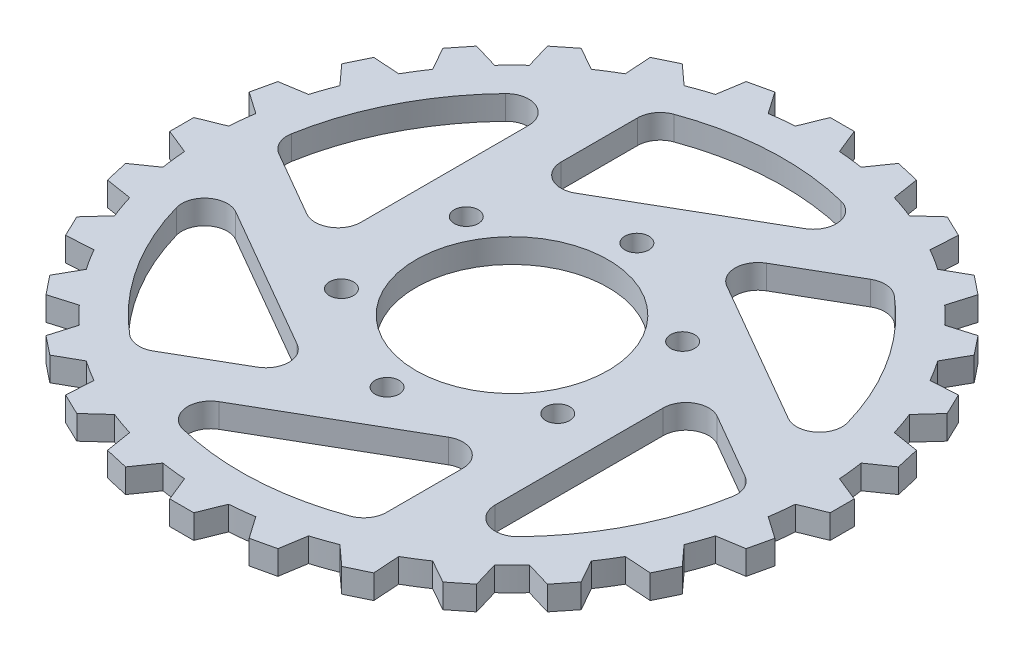
from build123d import *

# Parameters (mm, degrees)
SKETCH1_R           = 40
SKETCH1_R_2         = 5
BOSS_EXTRUDE1_DEPTH = 10


with BuildPart() as part:
    # Sketch1 → Boss-Extrude1 (new body)
    with BuildSketch(Plane(origin=(0, 0, 0), x_dir=(1, 0, 0), z_dir=(0, 1, 0))):
        with BuildLine():
            Line((-5, -137.5), (5, -137.5))
            Line((5, -137.5), (9.173776902, -127.16953966))
            ThreePointArc((9.173776902, -127.16953966), (14.275470703, -126.698306761), (19.354113574, -126.022491198))
            Line((19.354113574, -126.022491198), (25.721988858, -135.165192595))
            Line((25.721988858, -135.165192595), (35.47126798, -132.939983255))
            Line((35.47126798, -132.939983255), (37.241655898, -121.93977639))
            ThreePointArc((37.241655898, -121.93977639), (42.110580399, -120.345124614), (46.91150798, -118.556148803))
            Line((46.91150798, -118.556148803), (55.154169789, -126.052638032))
            Line((55.154169789, -126.052638032), (64.163858468, -121.713800641))
            Line((64.163858468, -121.713800641), (63.44208276, -110.595443555))
            ThreePointArc((63.44208276, -110.595443555), (67.834089756, -107.957335402), (72.11656349, -105.14490606))
            Line((72.11656349, -105.14490606), (81.820690343, -110.619277849))
            Line((81.820690343, -110.619277849), (89.639005168, -104.38437983))
            Line((89.639005168, -104.38437983), (86.46125868, -93.705393374))
            ThreePointArc((86.46125868, -93.705393374), (90.156114601, -90.156114601), (93.705393374, -86.46125868))
            Line((93.705393374, -86.46125868), (104.38437983, -89.639005168))
            Line((104.38437983, -89.639005168), (110.619277849, -81.820690343))
            Line((110.619277849, -81.820690343), (105.14490606, -72.11656349))
            ThreePointArc((105.14490606, -72.11656349), (107.957335402, -67.834089756), (110.595443555, -63.44208276))
            Line((110.595443555, -63.44208276), (121.713800641, -64.163858468))
            Line((121.713800641, -64.163858468), (126.052638032, -55.154169789))
            Line((126.052638032, -55.154169789), (118.556148803, -46.91150798))
            ThreePointArc((118.556148803, -46.91150798), (120.345124614, -42.110580399), (121.93977639, -37.241655898))
            Line((121.93977639, -37.241655898), (132.939983255, -35.47126798))
            Line((132.939983255, -35.47126798), (135.165192595, -25.721988858))
            Line((135.165192595, -25.721988858), (126.022491198, -19.354113574))
            ThreePointArc((126.022491198, -19.354113574), (126.698306761, -14.275470703), (127.16953966, -9.173776902))
            Line((127.16953966, -9.173776902), (137.5, -5))
            Line((137.5, -5), (137.5, 5))
            Line((137.5, 5), (127.16953966, 9.173776902))
            ThreePointArc((127.16953966, 9.173776902), (126.698306761, 14.275470703), (126.022491198, 19.354113574))
            Line((126.022491198, 19.354113574), (135.165192595, 25.721988858))
            Line((135.165192595, 25.721988858), (132.939983255, 35.47126798))
            Line((132.939983255, 35.47126798), (121.93977639, 37.241655898))
            ThreePointArc((121.93977639, 37.241655898), (120.345124614, 42.110580399), (118.556148803, 46.91150798))
            Line((118.556148803, 46.91150798), (126.052638032, 55.154169789))
            Line((126.052638032, 55.154169789), (121.713800641, 64.163858468))
            Line((121.713800641, 64.163858468), (110.595443555, 63.44208276))
            ThreePointArc((110.595443555, 63.44208276), (107.957335402, 67.834089756), (105.14490606, 72.11656349))
            Line((105.14490606, 72.11656349), (110.619277849, 81.820690343))
            Line((110.619277849, 81.820690343), (104.38437983, 89.639005168))
            Line((104.38437983, 89.639005168), (93.705393374, 86.46125868))
            ThreePointArc((93.705393374, 86.46125868), (90.156114601, 90.156114601), (86.46125868, 93.705393374))
            Line((86.46125868, 93.705393374), (89.639005168, 104.38437983))
            Line((89.639005168, 104.38437983), (81.820690343, 110.619277849))
            Line((81.820690343, 110.619277849), (72.11656349, 105.14490606))
            ThreePointArc((72.11656349, 105.14490606), (67.834089756, 107.957335402), (63.44208276, 110.595443555))
            Line((63.44208276, 110.595443555), (64.163858468, 121.713800641))
            Line((64.163858468, 121.713800641), (55.154169789, 126.052638032))
            Line((55.154169789, 126.052638032), (46.91150798, 118.556148803))
            ThreePointArc((46.91150798, 118.556148803), (42.110580399, 120.345124614), (37.241655898, 121.93977639))
            Line((37.241655898, 121.93977639), (35.47126798, 132.939983255))
            Line((35.47126798, 132.939983255), (25.721988858, 135.165192595))
            Line((25.721988858, 135.165192595), (19.354113574, 126.022491198))
            ThreePointArc((19.354113574, 126.022491198), (14.275470703, 126.698306761), (9.173776902, 127.16953966))
            Line((9.173776902, 127.16953966), (5, 137.5))
            Line((5, 137.5), (-5, 137.5))
            Line((-5, 137.5), (-9.173776902, 127.16953966))
            ThreePointArc((-9.173776902, 127.16953966), (-14.275470703, 126.698306761), (-19.354113574, 126.022491198))
            Line((-19.354113574, 126.022491198), (-25.721988858, 135.165192595))
            Line((-25.721988858, 135.165192595), (-35.47126798, 132.939983255))
            Line((-35.47126798, 132.939983255), (-37.241655898, 121.93977639))
            ThreePointArc((-37.241655898, 121.93977639), (-42.110580399, 120.345124614), (-46.91150798, 118.556148803))
            Line((-46.91150798, 118.556148803), (-55.154169789, 126.052638032))
            Line((-55.154169789, 126.052638032), (-64.163858468, 121.713800641))
            Line((-64.163858468, 121.713800641), (-63.44208276, 110.595443555))
            ThreePointArc((-63.44208276, 110.595443555), (-67.834089756, 107.957335402), (-72.11656349, 105.14490606))
            Line((-72.11656349, 105.14490606), (-81.820690343, 110.619277849))
            Line((-81.820690343, 110.619277849), (-89.639005168, 104.38437983))
            Line((-89.639005168, 104.38437983), (-86.46125868, 93.705393374))
            ThreePointArc((-86.46125868, 93.705393374), (-90.156114601, 90.156114601), (-93.705393374, 86.46125868))
            Line((-93.705393374, 86.46125868), (-104.38437983, 89.639005168))
            Line((-104.38437983, 89.639005168), (-110.619277849, 81.820690343))
            Line((-110.619277849, 81.820690343), (-105.14490606, 72.11656349))
            ThreePointArc((-105.14490606, 72.11656349), (-107.957335402, 67.834089756), (-110.595443555, 63.44208276))
            Line((-110.595443555, 63.44208276), (-121.713800641, 64.163858468))
            Line((-121.713800641, 64.163858468), (-126.052638032, 55.154169789))
            Line((-126.052638032, 55.154169789), (-118.556148803, 46.91150798))
            ThreePointArc((-118.556148803, 46.91150798), (-120.345124614, 42.110580399), (-121.93977639, 37.241655898))
            Line((-121.93977639, 37.241655898), (-132.939983255, 35.47126798))
            Line((-132.939983255, 35.47126798), (-135.165192595, 25.721988858))
            Line((-135.165192595, 25.721988858), (-126.022491198, 19.354113574))
            ThreePointArc((-126.022491198, 19.354113574), (-126.698306761, 14.275470703), (-127.16953966, 9.173776902))
            Line((-127.16953966, 9.173776902), (-137.5, 5))
            Line((-137.5, 5), (-137.5, -5))
            Line((-137.5, -5), (-127.16953966, -9.173776902))
            ThreePointArc((-127.16953966, -9.173776902), (-126.698306761, -14.275470703), (-126.022491198, -19.354113574))
            Line((-126.022491198, -19.354113574), (-135.165192595, -25.721988858))
            Line((-135.165192595, -25.721988858), (-132.939983255, -35.47126798))
            Line((-132.939983255, -35.47126798), (-121.93977639, -37.241655898))
            ThreePointArc((-121.93977639, -37.241655898), (-120.345124614, -42.110580399), (-118.556148803, -46.91150798))
            Line((-118.556148803, -46.91150798), (-126.052638032, -55.154169789))
            Line((-126.052638032, -55.154169789), (-121.713800641, -64.163858468))
            Line((-121.713800641, -64.163858468), (-110.595443555, -63.44208276))
            ThreePointArc((-110.595443555, -63.44208276), (-107.957335402, -67.834089756), (-105.14490606, -72.11656349))
            Line((-105.14490606, -72.11656349), (-110.619277849, -81.820690343))
            Line((-110.619277849, -81.820690343), (-104.38437983, -89.639005168))
            Line((-104.38437983, -89.639005168), (-93.705393374, -86.46125868))
            ThreePointArc((-93.705393374, -86.46125868), (-90.156114601, -90.156114601), (-86.46125868, -93.705393374))
            Line((-86.46125868, -93.705393374), (-89.639005168, -104.38437983))
            Line((-89.639005168, -104.38437983), (-81.820690343, -110.619277849))
            Line((-81.820690343, -110.619277849), (-72.11656349, -105.14490606))
            ThreePointArc((-72.11656349, -105.14490606), (-67.834089756, -107.957335402), (-63.44208276, -110.595443555))
            Line((-63.44208276, -110.595443555), (-64.163858468, -121.713800641))
            Line((-64.163858468, -121.713800641), (-55.154169789, -126.052638032))
            Line((-55.154169789, -126.052638032), (-46.91150798, -118.556148803))
            ThreePointArc((-46.91150798, -118.556148803), (-42.110580399, -120.345124614), (-37.241655898, -121.93977639))
            Line((-37.241655898, -121.93977639), (-35.47126798, -132.939983255))
            Line((-35.47126798, -132.939983255), (-25.721988858, -135.165192595))
            Line((-25.721988858, -135.165192595), (-19.354113574, -126.022491198))
            ThreePointArc((-19.354113574, -126.022491198), (-14.275470703, -126.698306761), (-9.173776902, -127.16953966))
            Line((-9.173776902, -127.16953966), (-5, -137.5))
        make_face()
        with Locations(Location((0, 0, 0), (0, 0, 270))):  # turned: the seam where the file's is
            Circle(SKETCH1_R, mode=Mode.SUBTRACT)
        with Locations(Location((0, 52, 0), (0, 0, 270))):  # turned: the seam where the file's is
            Circle(SKETCH1_R_2, mode=Mode.SUBTRACT)
        with Locations(Location((45.033320997, 26, 0), (0, 0, 270))):  # turned: the seam where the file's is
            Circle(SKETCH1_R_2, mode=Mode.SUBTRACT)
        with Locations(Location((45.033320997, -26, 0), (0, 0, 270))):  # turned: the seam where the file's is
            Circle(SKETCH1_R_2, mode=Mode.SUBTRACT)
        with Locations(Location((0, -52, 0), (0, 0, 270))):  # turned: the seam where the file's is
            Circle(SKETCH1_R_2, mode=Mode.SUBTRACT)
        with Locations(Location((-45.033320997, -26, 0), (0, 0, 270))):  # turned: the seam where the file's is
            Circle(SKETCH1_R_2, mode=Mode.SUBTRACT)
        with Locations(Location((-45.033320997, 26, 0), (0, 0, 270))):  # turned: the seam where the file's is
            Circle(SKETCH1_R_2, mode=Mode.SUBTRACT)
        with BuildLine():
            Line((-45, 97.221396822), (-45, 65.454482672))
            ThreePointArc((-45, 65.454482672), (-40.25, 57.227241336), (-30.75, 57.227241336))
            Line((-30.75, 57.227241336), (29.811854566, 92.192644372))
            ThreePointArc((29.811854566, 92.192644372), (34.469552159, 101.740955732), (27.362218029, 109.637169904))
            ThreePointArc((27.362218029, 109.637169904), (-5.959629803, 112.842734869), (-38.758454106, 106.145099912))
            ThreePointArc((-38.758454106, 106.145099912), (-43.284770838, 102.666334195), (-45, 97.221396822))
        make_face(mode=Mode.SUBTRACT)
        with BuildLine():
            Line((61.696199439, 87.581841581), (34.185244785, 71.698384506))
            ThreePointArc((34.185244785, 71.698384506), (29.435244785, 63.47114317), (34.185244785, 55.243901834))
            Line((34.185244785, 55.243901834), (94.747099352, 20.278498798))
            ThreePointArc((94.747099352, 20.278498798), (105.345028349, 21.018970039), (108.62968335, 31.122209035))
            ThreePointArc((108.62968335, 31.122209035), (94.744860127, 61.582558241), (72.545125958, 86.638355823))
            ThreePointArc((72.545125958, 86.638355823), (67.269268107, 88.81887824), (61.696199439, 87.581841581))
        make_face(mode=Mode.SUBTRACT)
        with BuildLine():
            Line((106.696199439, -9.639555241), (79.185244785, 6.243901834))
            ThreePointArc((79.185244785, 6.243901834), (69.685244785, 6.243901834), (64.935244785, -1.983339502))
            Line((64.935244785, -1.983339502), (64.935244785, -71.914145575))
            ThreePointArc((64.935244785, -71.914145575), (70.87547619, -80.721985693), (81.267465321, -78.514960869))
            ThreePointArc((81.267465321, -78.514960869), (100.70448993, -51.260176628), (111.303580064, -19.506744088))
            ThreePointArc((111.303580064, -19.506744088), (110.554038945, -13.847455954), (106.696199439, -9.639555241))
        make_face(mode=Mode.SUBTRACT)
        with BuildLine():
            Line((45, -97.221396822), (45, -65.454482672))
            ThreePointArc((45, -65.454482672), (40.25, -57.227241336), (30.75, -57.227241336))
            Line((30.75, -57.227241336), (-29.811854566, -92.192644372))
            ThreePointArc((-29.811854566, -92.192644372), (-34.469552159, -101.740955732), (-27.362218029, -109.637169904))
            ThreePointArc((-27.362218029, -109.637169904), (5.959629803, -112.842734869), (38.758454106, -106.145099912))
            ThreePointArc((38.758454106, -106.145099912), (43.284770838, -102.666334195), (45, -97.221396822))
        make_face(mode=Mode.SUBTRACT)
        with BuildLine():
            Line((-61.696199439, -87.581841581), (-34.185244785, -71.698384506))
            ThreePointArc((-34.185244785, -71.698384506), (-29.435244785, -63.47114317), (-34.185244785, -55.243901834))
            Line((-34.185244785, -55.243901834), (-94.747099352, -20.278498798))
            ThreePointArc((-94.747099352, -20.278498798), (-105.345028349, -21.018970039), (-108.62968335, -31.122209035))
            ThreePointArc((-108.62968335, -31.122209035), (-94.744860127, -61.582558241), (-72.545125958, -86.638355823))
            ThreePointArc((-72.545125958, -86.638355823), (-67.269268107, -88.81887824), (-61.696199439, -87.581841581))
        make_face(mode=Mode.SUBTRACT)
        with BuildLine():
            Line((-106.696199439, 9.639555241), (-79.185244785, -6.243901834))
            ThreePointArc((-79.185244785, -6.243901834), (-69.685244785, -6.243901834), (-64.935244785, 1.983339502))
            Line((-64.935244785, 1.983339502), (-64.935244785, 71.914145575))
            ThreePointArc((-64.935244785, 71.914145575), (-70.87547619, 80.721985693), (-81.267465321, 78.514960869))
            ThreePointArc((-81.267465321, 78.514960869), (-100.70448993, 51.260176628), (-111.303580064, 19.506744088))
            ThreePointArc((-111.303580064, 19.506744088), (-110.554038945, 13.847455954), (-106.696199439, 9.639555241))
        make_face(mode=Mode.SUBTRACT)
    extrude(amount=BOSS_EXTRUDE1_DEPTH)


solid = part.part
